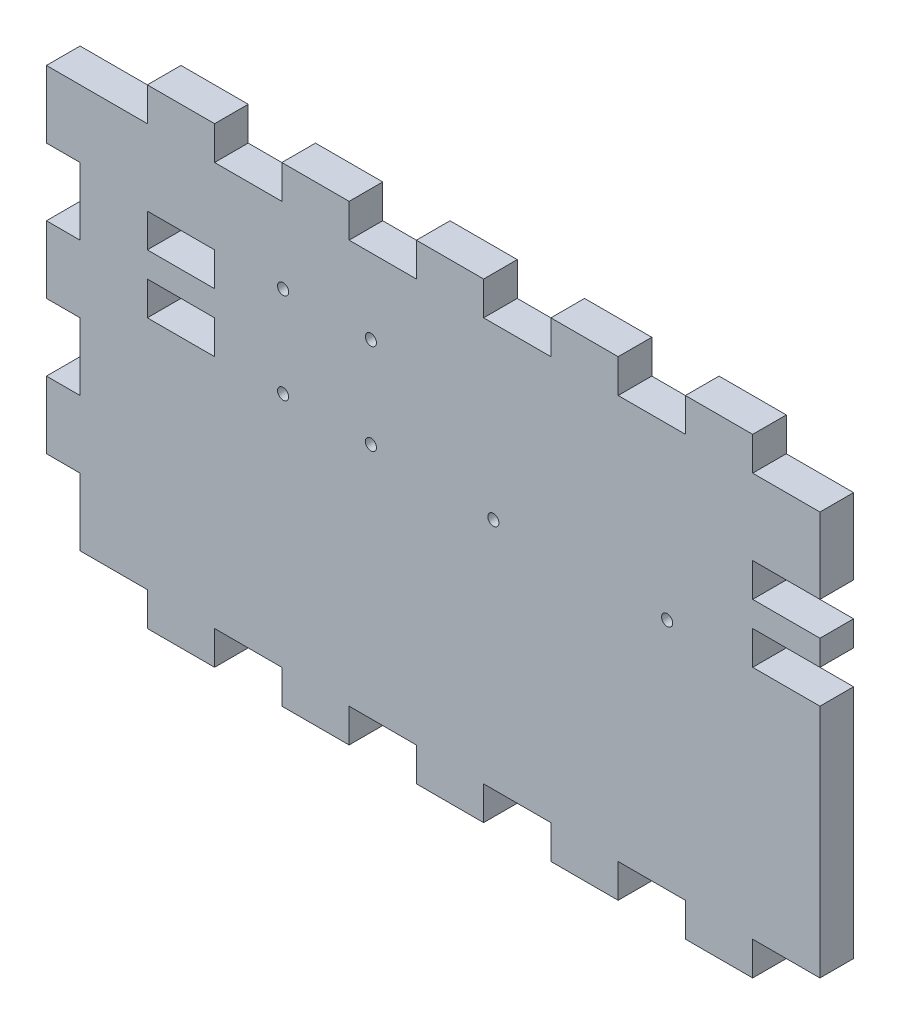
from build123d import *

# Parameters (mm, degrees)
SKETCH1_W               = 279.4
SKETCH1_H               = 152.4
BOSS_EXTRUDE1_DEPTH     = 12.7
SKETCH2_W               = 25.4
SKETCH2_H               = 12.7
BOSS_EXTRUDE2_DEPTH     = 12.7
LPATTERN1_COUNT         = 5
LPATTERN1_PITCH         = 50.8
MIRROR1_COPY_1_SKETCH_W = 25.4
MIRROR1_COPY_1_SKETCH_H = 12.7
MIRROR1_COPY_1_DEPTH    = 12.7
MIRROR1_COPY_2_SKETCH_W = 25.4
MIRROR1_COPY_2_SKETCH_H = 12.7
MIRROR1_COPY_2_DEPTH    = 12.7
MIRROR1_COPY_3_SKETCH_W = 25.4
MIRROR1_COPY_3_SKETCH_H = 12.7
MIRROR1_COPY_3_DEPTH    = 12.7
MIRROR1_COPY_4_SKETCH_W = 25.4
MIRROR1_COPY_4_SKETCH_H = 12.7
MIRROR1_COPY_4_DEPTH    = 12.7
SKETCH3_W               = 12.7
SKETCH3_H               = 25.4
BOSS_EXTRUDE3_DEPTH     = 12.7
LPATTERN2_COUNT         = 3
LPATTERN2_PITCH         = 50.8
SKETCH4_W               = 25.4
SKETCH4_H               = 12.7
CUT_EXTRUDE1_DEPTH      = 13.7
LPATTERN3_COUNT         = 2
LPATTERN3_PITCH         = 228.6
SKETCH5_W               = 25.4
SKETCH5_H               = 12.7
CUT_EXTRUDE2_DEPTH      = 13.7
LPATTERN4_COUNT         = 2
LPATTERN4_PITCH         = 228.6
SKETCH6_R               = 2.1
CUT_EXTRUDE3_DEPTH      = 13.7


with BuildPart() as part:
    # Sketch1 → Boss-Extrude1 (new body)
    with BuildSketch(Plane.XY):
        Rectangle(SKETCH1_W, SKETCH1_H)
    extrude(amount=BOSS_EXTRUDE1_DEPTH)

    # Sketch2 → Boss-Extrude2 (add)
    with BuildSketch(Plane.XZ.offset(76.2)):
        with Locations((-101.6, 6.35)):
            Rectangle(SKETCH2_W, SKETCH2_H)
    boss_extrude2 = extrude(amount=BOSS_EXTRUDE2_DEPTH)

    # LPattern1: Boss-Extrude2 ×5
    with Locations(*[(i * LPATTERN1_PITCH, 0, 0) for i in range(1, LPATTERN1_COUNT)]):
        add(boss_extrude2)

    # Mirror1: Boss-Extrude2 across plane
    add(boss_extrude2.mirror(Plane.ZX))

    # Mirror1 copy 1 sketch → Mirror1 copy 1 (add)
    with BuildSketch(Plane(origin=(50.8, 76.2, 0), x_dir=(1, 0, 0), z_dir=(0, 1, 0))):
        with Locations((-101.6, -6.35)):
            Rectangle(MIRROR1_COPY_1_SKETCH_W, MIRROR1_COPY_1_SKETCH_H)
    extrude(amount=MIRROR1_COPY_1_DEPTH)

    # Mirror1 copy 2 sketch → Mirror1 copy 2 (add)
    with BuildSketch(Plane(origin=(101.6, 76.2, 0), x_dir=(1, 0, 0), z_dir=(0, 1, 0))):
        with Locations((-101.6, -6.35)):
            Rectangle(MIRROR1_COPY_2_SKETCH_W, MIRROR1_COPY_2_SKETCH_H)
    extrude(amount=MIRROR1_COPY_2_DEPTH)

    # Mirror1 copy 3 sketch → Mirror1 copy 3 (add)
    with BuildSketch(Plane(origin=(152.4, 76.2, 0), x_dir=(1, 0, 0), z_dir=(0, 1, 0))):
        with Locations((-101.6, -6.35)):
            Rectangle(MIRROR1_COPY_3_SKETCH_W, MIRROR1_COPY_3_SKETCH_H)
    extrude(amount=MIRROR1_COPY_3_DEPTH)

    # Mirror1 copy 4 sketch → Mirror1 copy 4 (add)
    with BuildSketch(Plane(origin=(203.2, 76.2, 0), x_dir=(1, 0, 0), z_dir=(0, 1, 0))):
        with Locations((-101.6, -6.35)):
            Rectangle(MIRROR1_COPY_4_SKETCH_W, MIRROR1_COPY_4_SKETCH_H)
    extrude(amount=MIRROR1_COPY_4_DEPTH)

    # Sketch3 → Boss-Extrude3 (add)
    with BuildSketch(Plane.ZY.offset(139.7)):
        with Locations((6.35, 63.5)):
            Rectangle(SKETCH3_W, SKETCH3_H)
    boss_extrude3 = extrude(amount=BOSS_EXTRUDE3_DEPTH)

    # LPattern2: Boss-Extrude3 ×3
    with Locations(*[(0, -i * LPATTERN2_PITCH, 0) for i in range(1, LPATTERN2_COUNT)]):
        add(boss_extrude3)

    # Sketch4 → Cut-Extrude1 (cut, through all)
    with BuildSketch(Plane(origin=(0, 0, 0), x_dir=(-1, 0, 0), z_dir=(0, 0, -1))):
        with Locations((-127, 19.05)):
            Rectangle(SKETCH4_W, SKETCH4_H)
    cut_extrude1 = extrude(amount=-CUT_EXTRUDE1_DEPTH, mode=Mode.SUBTRACT)

    # LPattern3: Cut-Extrude1 ×2
    with Locations(*[(-i * LPATTERN3_PITCH, 0, 0) for i in range(1, LPATTERN3_COUNT)]):
        add(cut_extrude1, mode=Mode.SUBTRACT)

    # Sketch5 → Cut-Extrude2 (cut, through all)
    with BuildSketch(Plane.XY.offset(12.7)):
        with Locations((-101.6, 41.275)):
            Rectangle(SKETCH5_W, SKETCH5_H)
    cut_extrude2 = extrude(amount=-CUT_EXTRUDE2_DEPTH, mode=Mode.SUBTRACT)

    # LPattern4: Cut-Extrude2 ×2
    with Locations(*[(i * LPATTERN4_PITCH, 0, 0) for i in range(1, LPATTERN4_COUNT)]):
        add(cut_extrude2, mode=Mode.SUBTRACT)

    # Sketch6 → Cut-Extrude3 (cut, through all)
    with BuildSketch(Plane(origin=(0, 0, 0), x_dir=(-1, 0, 0), z_dir=(0, 0, -1))):
        with Locations((-81.986081859, 12)):
            Circle(SKETCH6_R)
        with Locations((-16.378881859, 12)):
            Circle(SKETCH6_R)
        with Locations((63.020004141, 13.50877)):
            Circle(SKETCH6_R)
        with Locations((29.870004141, 47.77)):
            Circle(SKETCH6_R)
        with Locations((63.020004141, 47.77)):
            Circle(SKETCH6_R)
        with Locations((29.870004141, 13.50877)):
            Circle(SKETCH6_R)
    extrude(amount=-CUT_EXTRUDE3_DEPTH, mode=Mode.SUBTRACT)


solid = part.part
